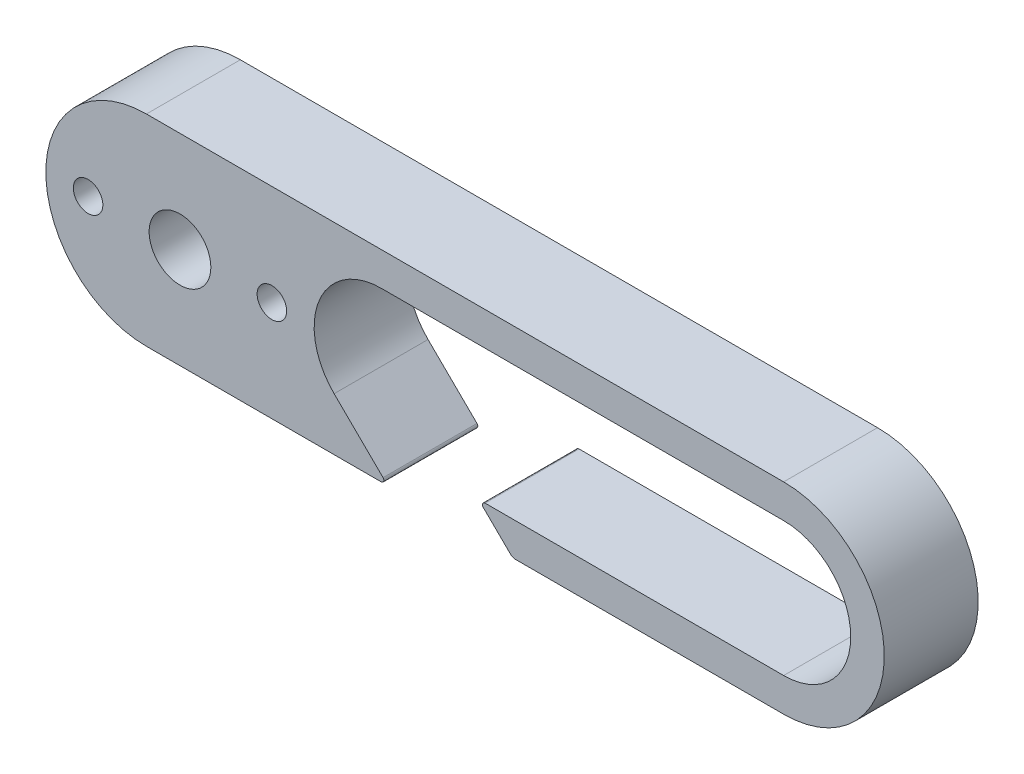
from build123d import *

# Parameters (mm, degrees)
SKETCH2_R           = 2.3
SKETCH2_R_2         = 1.1
BOSS_EXTRUDE1_DEPTH = 7


with BuildPart() as part:
    # Sketch2 → Boss-Extrude1 (new body)
    with BuildSketch(Plane.XY):
        with BuildLine():
            Line((16.77037128, 5), (46.77037128, 5))
            ThreePointArc((46.77037128, 5), (51.770370099, 0), (46.77037128, -5))
            Line((46.77037128, -5), (24.516048425, -5))
            ThreePointArc((24.516048425, -5), (24.330990192, -5.124148498), (24.375678975, -5.342465496))
            Line((24.375678975, -5.342465496), (26.419446474, -7.35616374))
            ThreePointArc((26.419446474, -7.35616374), (26.580741343, -7.462645583), (26.770370099, -7.5))
            Line((26.770370099, -7.5), (46.77037187, -7.5))
            ThreePointArc((46.77037187, -7.5), (54.270370099, 2.95e-07), (46.77037128, 7.5))
            Line((46.77037128, 7.5), (-0.729629901, 7.5))
            ThreePointArc((-0.729629901, 7.5), (-8.229629901, 0), (-0.729629901, -7.5))
            Line((-0.729629901, -7.5), (16.770370099, -7.5))
            ThreePointArc((16.770370099, -7.5), (16.95577733, -7.374994391), (16.909415122, -7.156241586))
            Line((16.909415122, -7.156241586), (13.261135036, -3.561637402))
            ThreePointArc((13.261135036, -3.561637402), (12.143915454, 1.896287556), (16.77037128, 5))
        make_face()
        with Locations((1.770370689, 0)):
            Circle(SKETCH2_R, mode=Mode.SUBTRACT)
        with Locations((8.620370689, 0)):
            Circle(SKETCH2_R_2, mode=Mode.SUBTRACT)
        with Locations((-5.079629311, 0)):
            Circle(SKETCH2_R_2, mode=Mode.SUBTRACT)
    extrude(amount=BOSS_EXTRUDE1_DEPTH)


solid = part.part
